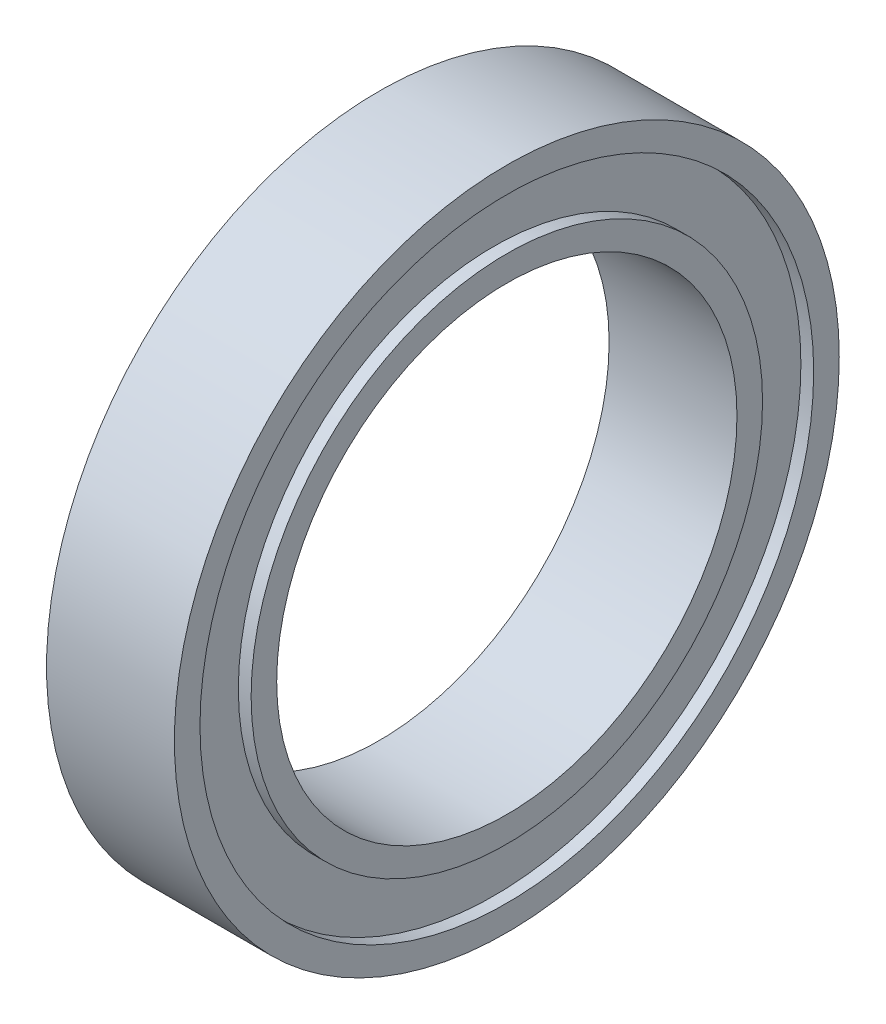
from build123d import *

# Parameters (mm, degrees)
SKETCH2_R           = 13
BOSS_EXTRUDE1_DEPTH = 2.5
SKETCH3_R           = 9
CUT_EXTRUDE1_DEPTH  = 6
SKETCH4_R           = 12
SKETCH4_R_2         = 11
SKETCH4_R_3         = 10
CUT_EXTRUDE2_DEPTH  = 0.5


with BuildPart() as part:
    # Sketch2 → Boss-Extrude1 (new, symmetric)
    with BuildSketch(Plane(origin=(0, 0, 0), x_dir=(0, 0, -1), z_dir=(1, 0, 0))):
        Circle(SKETCH2_R)
    extrude(amount=BOSS_EXTRUDE1_DEPTH, both=True)

    # Sketch3 → Cut-Extrude1 (cut)
    with BuildSketch(Plane(origin=(2.5, 0, 0), x_dir=(0, 0, -1), z_dir=(1, 0, 0))):
        Circle(SKETCH3_R)
    extrude(amount=-CUT_EXTRUDE1_DEPTH, mode=Mode.SUBTRACT)

    # Sketch4 → Cut-Extrude2 (cut)
    with BuildSketch(Plane(origin=(2.5, 0, 0), x_dir=(0, 0, -1), z_dir=(1, 0, 0))):
        Circle(SKETCH4_R)
        Circle(SKETCH4_R_2, mode=Mode.SUBTRACT)
        Circle(SKETCH4_R_2)
        Circle(SKETCH4_R_3, mode=Mode.SUBTRACT)
    cut_extrude2 = extrude(amount=-CUT_EXTRUDE2_DEPTH, mode=Mode.SUBTRACT)

    # Mirror1: Cut-Extrude2 across plane
    add(cut_extrude2.mirror(Plane(origin=(0, 0, 0), x_dir=(0, 0, 1), z_dir=(1, 0, 0))), mode=Mode.SUBTRACT)


solid = part.part
